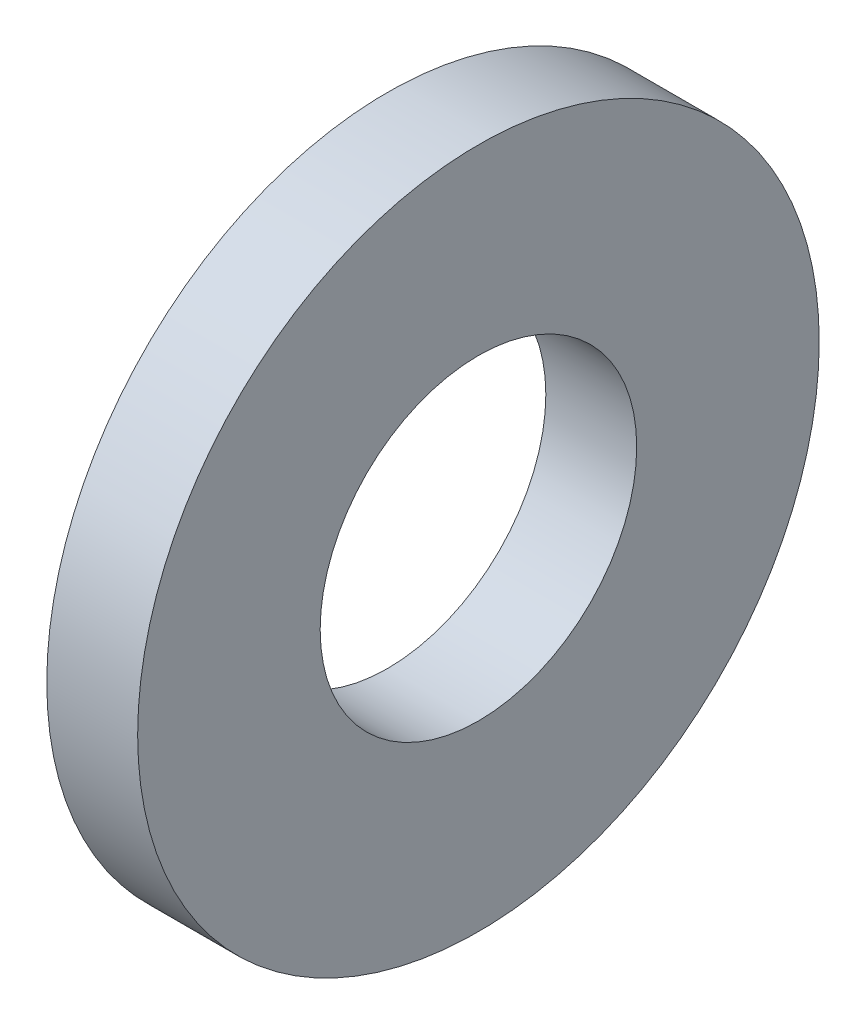
from build123d import *

# Parameters (mm, degrees)
SKETCH1_W = 1.2
SKETCH1_H = 2.41


with BuildPart() as part:
    # Sketch1 → Base-Revolve (revolve)
    with BuildSketch(Plane.XY):
        with Locations((-0.6, 3.295)):
            Rectangle(SKETCH1_W, SKETCH1_H)
    revolve(axis=Axis((-34.925, 0, 0), (1, 0, 0)))


solid = part.part
